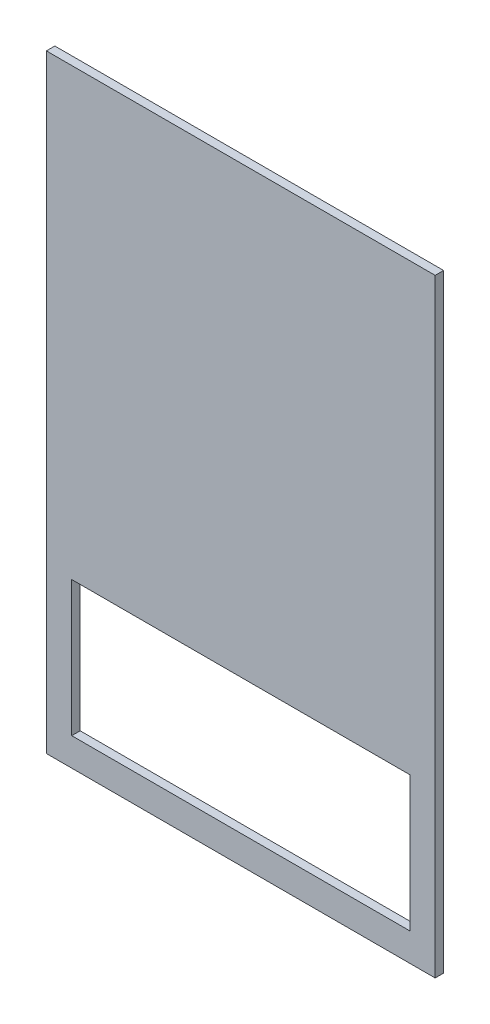
from build123d import *

# Parameters (mm, degrees)
SKETCH1_W           = 584.2
SKETCH1_H           = 914.4
BOSS_EXTRUDE1_DEPTH = 12.7
SKETCH2_W           = 508
SKETCH2_H           = 203.2
CUT_EXTRUDE1_DEPTH  = 13.7


with BuildPart() as part:
    # Sketch1 → Boss-Extrude1 (new body)
    with BuildSketch(Plane.XY):
        Rectangle(SKETCH1_W, SKETCH1_H)
    extrude(amount=BOSS_EXTRUDE1_DEPTH)

    # Sketch2 → Cut-Extrude1 (cut, through all)
    with BuildSketch(Plane.XY.offset(12.7)):
        with Locations((0, -313.309)):
            Rectangle(SKETCH2_W, SKETCH2_H)
    extrude(amount=-CUT_EXTRUDE1_DEPTH, mode=Mode.SUBTRACT)


solid = part.part
